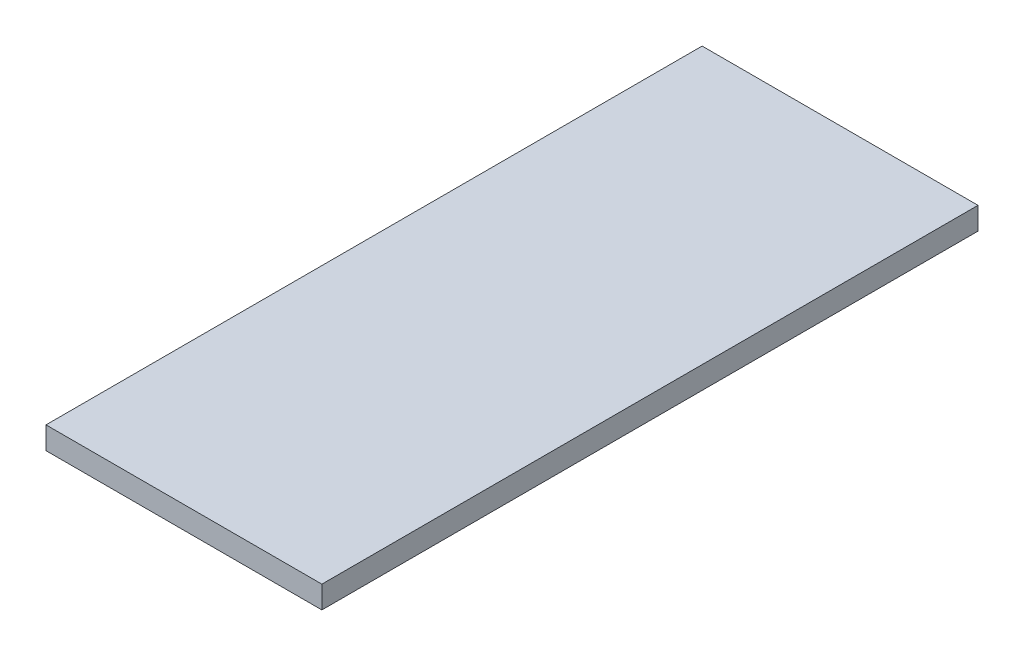
from build123d import *

# Parameters (mm, degrees)
SKETCH1_W           = 37
SKETCH1_H           = 88
BOSS_EXTRUDE1_DEPTH = 3


with BuildPart() as part:
    # Sketch1 → Boss-Extrude1 (new body)
    with BuildSketch(Plane(origin=(0, 0, 0), x_dir=(1, 0, 0), z_dir=(0, 1, 0))):
        with Locations((18.5, 44)):
            Rectangle(SKETCH1_W, SKETCH1_H)
    extrude(amount=BOSS_EXTRUDE1_DEPTH)


solid = part.part
